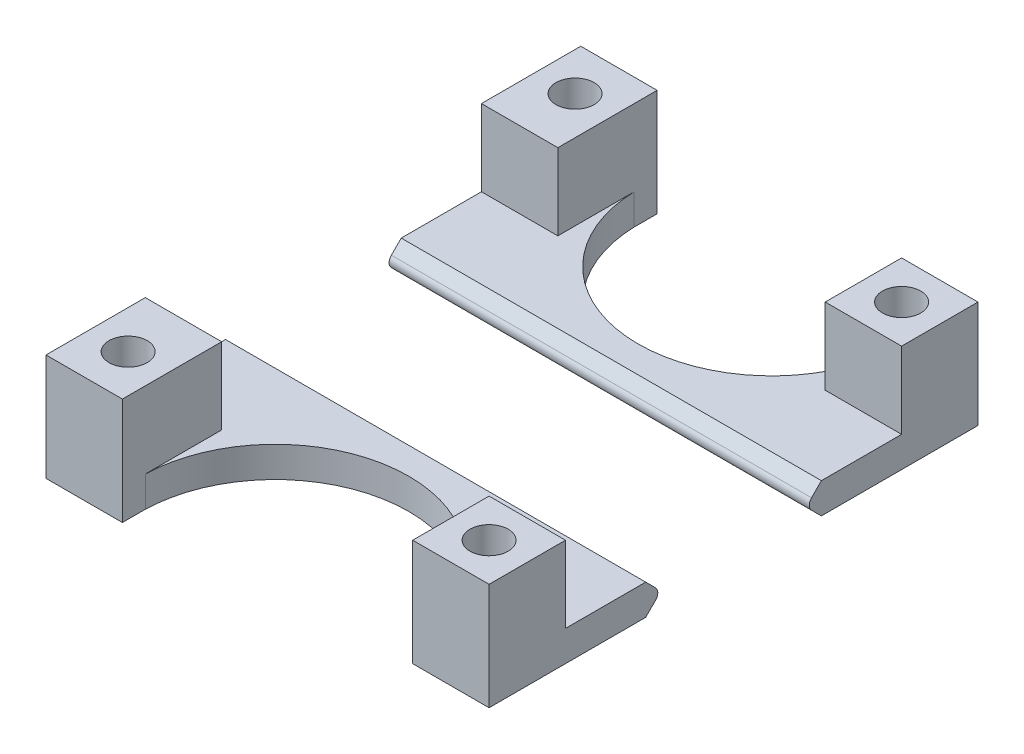
from build123d import *

# Parameters (mm, degrees)
SKETCH1_R           = 2.5
EXTRUDE_BODY_DEPTH  = 4
SKETCH5_W           = 10
SKETCH5_H           = 10
SKETCH5_R           = 2.5
SKETCH5_H_2         = 13
EXTRUDE_LEGS_DEPTH  = 10
SKETCH6_W           = 45
SKETCH6_H           = 0.5
BOSS_EXTRUDE1_DEPTH = 4
CUT_EXTRUDE1_DEPTH  = 55
SKETCH8_W           = 10
SKETCH8_H           = 19
CUT_EXTRUDE2_DEPTH  = 10


with BuildPart() as part:
    # Sketch1 → Extrude-Body (new body)
    with BuildSketch(Plane(origin=(0, 0, 0), x_dir=(1, 0, 0), z_dir=(0, 1, 0))):
        with BuildLine():
            Line((10, 10), (10, -10))
            Line((10, -10), (45, -10))
            Line((45, -10), (55, -10))
            Line((55, -10), (55, -20))
            Line((55, -20), (55, -32))
            Line((55, -32), (45, -32))
            ThreePointArc((45, -32), (27.5, -15), (10, -32))
            Line((10, -32), (10, -35))
            Line((10, -35), (0, -35))
            Line((0, -35), (0, -32))
            Line((0, -32), (0, -20))
            Line((0, -20), (0, 20))
            Line((0, 20), (0, 32))
            Line((0, 32), (0, 35))
            Line((0, 35), (10, 35))
            Line((10, 35), (10, 32))
            ThreePointArc((10, 32), (27.5, 15), (45, 32))
            Line((45, 32), (55, 32))
            Line((55, 32), (55, 20))
            Line((55, 20), (55, 10))
            Line((55, 10), (45, 10))
            Line((45, 10), (10, 10))
        make_face()
        with Locations((50, 27)):
            Circle(SKETCH1_R, mode=Mode.SUBTRACT)
        with Locations((50, -27)):
            Circle(SKETCH1_R, mode=Mode.SUBTRACT)
        with Locations((5, 29.25)):
            Circle(SKETCH1_R, mode=Mode.SUBTRACT)
        with Locations((5, -29.25)):
            Circle(SKETCH1_R, mode=Mode.SUBTRACT)
    extrude(amount=EXTRUDE_BODY_DEPTH)

    # Sketch5 → Extrude-Legs (add)
    with BuildSketch(Plane(origin=(0, 4, 0), x_dir=(1, 0, 0), z_dir=(0, 1, 0))):
        with Locations((50, -27)):
            Rectangle(SKETCH5_W, SKETCH5_H)
        with Locations((50, -27)):
            Circle(SKETCH5_R, mode=Mode.SUBTRACT)
        with Locations((50, 27)):
            Rectangle(SKETCH5_W, SKETCH5_H)
        with Locations((50, 27)):
            Circle(SKETCH5_R, mode=Mode.SUBTRACT)
        with Locations((5, 28.5)):
            Rectangle(SKETCH5_W, SKETCH5_H_2)
        with Locations((5, 29.25)):
            Circle(SKETCH5_R, mode=Mode.SUBTRACT)
        with Locations((5, -28.5)):
            Rectangle(SKETCH5_W, SKETCH5_H_2)
        with Locations((5, -29.25)):
            Circle(SKETCH5_R, mode=Mode.SUBTRACT)
    extrude(amount=EXTRUDE_LEGS_DEPTH)

    # Sketch6 → Boss-Extrude1 (add)
    with BuildSketch(Plane(origin=(0, 4, 0), x_dir=(1, 0, 0), z_dir=(0, 1, 0))):
        with Locations((32.5, -9.75)):
            Rectangle(SKETCH6_W, SKETCH6_H)
        with Locations((32.5, 9.75)):
            Rectangle(SKETCH6_W, SKETCH6_H)
    extrude(amount=-BOSS_EXTRUDE1_DEPTH)

    # Sketch7 → Cut-Extrude1 (cut)
    with BuildSketch(Plane(origin=(55, 0, 0), x_dir=(0, 0, -1), z_dir=(1, 0, 0))):
        with BuildLine():
            Line((-10.207106781, 2.707106781), (-11.5, 4))
            Line((-11.5, 4), (-9.5, 4))
            Line((-9.5, 4), (-9.5, 0))
            Line((-9.5, 0), (-11.5, 0))
            Line((-11.5, 0), (-10.207106781, 1.292893219))
            ThreePointArc((-10.207106781, 1.292893219), (-9.914213562, 2), (-10.207106781, 2.707106781))
        make_face()
        with BuildLine():
            Line((10.207106781, 2.707106781), (11.5, 4))
            Line((11.5, 4), (9.5, 4))
            Line((9.5, 4), (9.5, 0))
            Line((9.5, 0), (11.5, 0))
            Line((11.5, 0), (10.207106781, 1.292893219))
            ThreePointArc((10.207106781, 1.292893219), (9.914213562, 2), (10.207106781, 2.707106781))
        make_face()
    extrude(amount=-CUT_EXTRUDE1_DEPTH, mode=Mode.SUBTRACT)

    # Sketch8 → Cut-Extrude2 (cut)
    with BuildSketch(Plane(origin=(0, 4, 0), x_dir=(1, 0, 0), z_dir=(0, 1, 0))):
        with Locations((5, 0)):
            Rectangle(SKETCH8_W, SKETCH8_H)
    extrude(amount=-CUT_EXTRUDE2_DEPTH, mode=Mode.SUBTRACT)


solid = part.part
